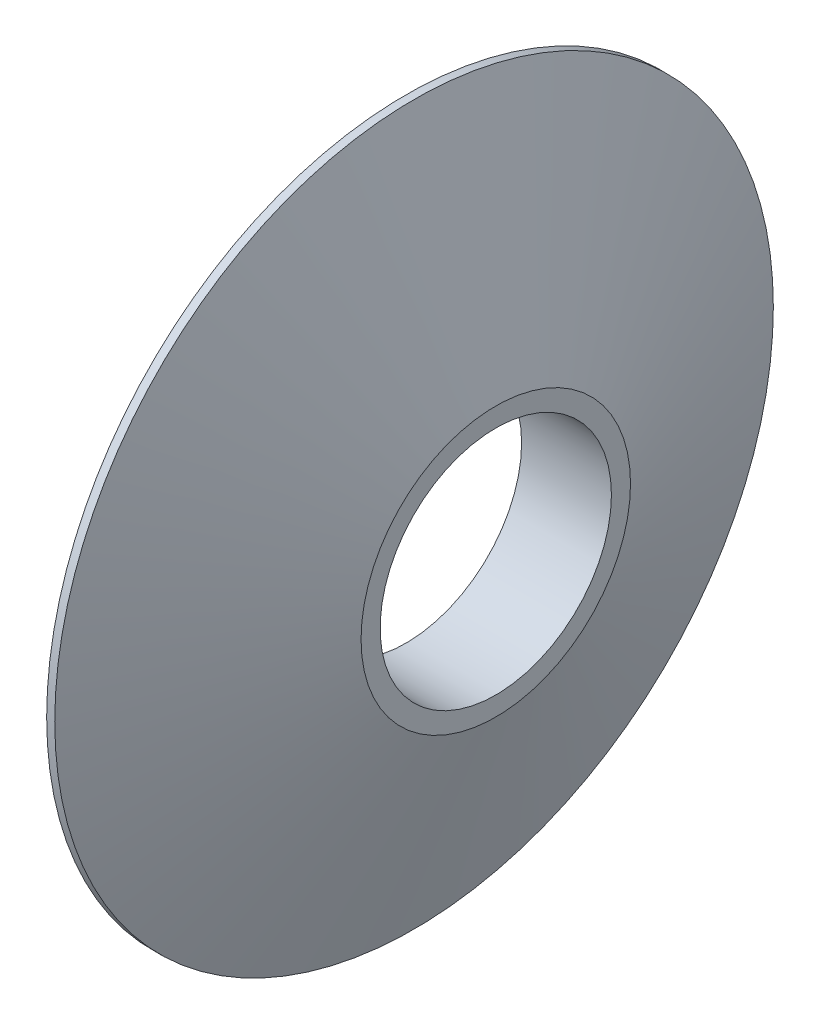
from build123d import *

# Parameters (mm, degrees)
SKETCH5_R          = 2.575
CUT_EXTRUDE3_DEPTH = 3


with BuildPart() as part:
    # Sketch1 → Revolve1 (revolve)
    with BuildSketch(Plane.XY):
        Polygon((0, 0), (0, 8), (0.180148829, 8), (2, 3), (2, 0), align=None)
    revolve(axis=Axis((-13.276595745, 0, 0), (1, 0, 0)))

    # Sketch5 → Cut-Extrude3 (cut, through all)
    with BuildSketch(Plane(origin=(2, 0, 0), x_dir=(0, 0, -1), z_dir=(1, 0, 0))):
        Circle(SKETCH5_R)
    extrude(amount=-CUT_EXTRUDE3_DEPTH, mode=Mode.SUBTRACT)


solid = part.part
